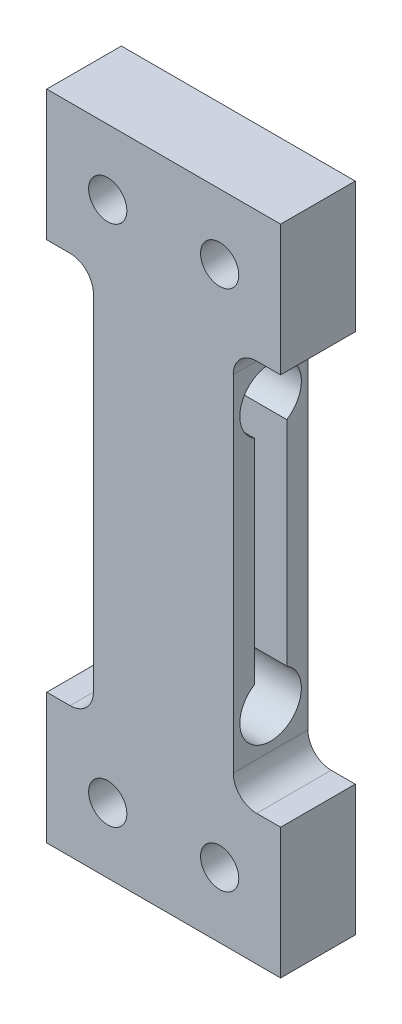
from build123d import *

# Parameters (mm, degrees)
SKETCH1_W                = 12.538434267
SKETCH1_H                = 35
BOSS_EXTRUDE1_DEPTH      = 4
SKETCH2_W                = 2.5
SKETCH2_H                = 21
CUT_EXTRUDE1_DEPTH       = 5
SKETCH3_W                = 2.538434267
SKETCH3_H                = 21
CUT_EXTRUDE2_DEPTH       = 5
CUT_EXTRUDE3_DEPTH       = 11.038434267
SKETCH5_W                = 7.5
SKETCH5_H                = 1.65
SKETCH6_W                = 7.5
SKETCH6_H                = 1.65
M2_5X0_45_TAPPED_HOLE1_D = 2.05
FILLET1_R                = 1.25


with BuildPart() as part:
    # Sketch1 → Boss-Extrude1 (new body)
    with BuildSketch(Plane.XY.offset(4)):
        with Locations((-3.730782867, 17.5)):
            Rectangle(SKETCH1_W, SKETCH1_H)
    extrude(amount=-BOSS_EXTRUDE1_DEPTH)

    # Sketch2 → Cut-Extrude1 (cut, through all)
    with BuildSketch(Plane(origin=(0, 0, 0), x_dir=(-1, 0, 0), z_dir=(0, 0, -1))):
        with Locations((8.75, 17.5)):
            Rectangle(SKETCH2_W, SKETCH2_H)
    extrude(amount=-CUT_EXTRUDE1_DEPTH, mode=Mode.SUBTRACT)

    # Sketch3 → Cut-Extrude2 (cut, through all)
    with BuildSketch(Plane(origin=(0, 0, 0), x_dir=(-1, 0, 0), z_dir=(0, 0, -1))):
        with Locations((-1.269217133, 17.5)):
            Rectangle(SKETCH3_W, SKETCH3_H)
    extrude(amount=-CUT_EXTRUDE2_DEPTH, mode=Mode.SUBTRACT)

    # Sketch4 → Cut-Extrude3 (cut, through all)
    with BuildSketch(Plane.ZY.offset(7.5)):
        with BuildLine():
            Line((2.855933763, 11.78563014), (2.855933763, 23.21436986))
            ThreePointArc((2.855933763, 23.21436986), (1.992824856, 22.975015601), (1.13183027, 23.221867319))
            Line((1.13183027, 23.221867319), (1.13183027, 11.778132681))
            ThreePointArc((1.13183027, 11.778132681), (1.992824856, 12.024984399), (2.855933763, 11.78563014))
        make_face()
    extrude(amount=-CUT_EXTRUDE3_DEPTH, mode=Mode.SUBTRACT)

    # Sketch5 → Cut-Revolve1 (revolve, cut)
    with BuildSketch(Plane(origin=(0, 0, 2), x_dir=(-1, 0, 0), z_dir=(0, 0, -1))):
        with Locations((3.75, 25.45)):
            Rectangle(SKETCH5_W, SKETCH5_H)
    revolve(axis=Axis((0, 24.625, 2), (-1, 0, 0)), mode=Mode.SUBTRACT)

    # Sketch6 → Cut-Revolve2 (revolve, cut)
    with BuildSketch(Plane(origin=(0, 0, 2), x_dir=(-1, 0, 0), z_dir=(0, 0, -1))):
        with Locations((3.75, 11.2)):
            Rectangle(SKETCH6_W, SKETCH6_H)
    revolve(axis=Axis((0, 10.375, 2), (-1, 0, 0)), mode=Mode.SUBTRACT)

    # M2.5x0.45 Tapped Hole1 (through all)
    with Locations(Plane.XY.offset(4)):
        with Locations((-0.730782866, 3.5), (-6.730782866, 3.5), (-0.730782866, 31.5), (-6.730782866, 31.5)):
            Hole(M2_5X0_45_TAPPED_HOLE1_D / 2)

    # Fillet1
    fillet1_edges = [part.edges().sort_by_distance(p)[0] for p in [
        (-7.5, 7, 2),
        (-7.5, 28, 2),
        (0, 28, 2),
        (0, 7, 2),
    ]]
    fillet(fillet1_edges, radius=FILLET1_R)


solid = part.part
